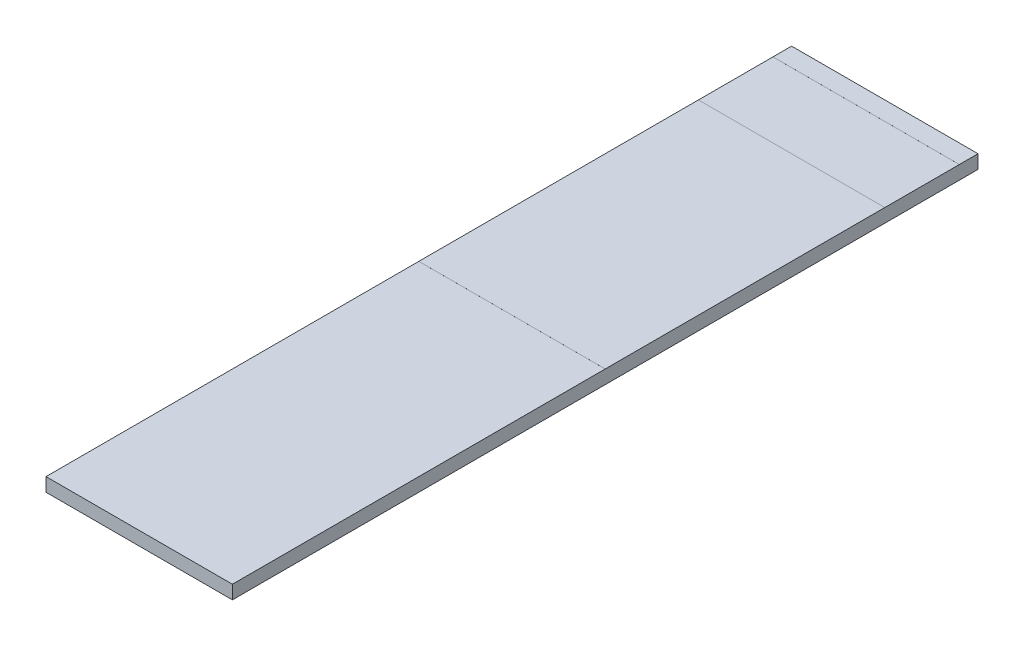
from build123d import *

# Parameters (mm, degrees)
SKETCH1_W           = 1
SKETCH1_H           = 0.072865
BOSS_EXTRUDE1_DEPTH = 4
SKETCH7_W           = 1
SKETCH7_H           = 0.1
SKETCH7_H_2         = 1.5
BOSS_EXTRUDE6_DEPTH = 0.0001
BOSS_EXTRUDE7_START = -0.072865
SKETCH7_2_W         = 1
SKETCH7_2_H         = 0.1
SKETCH7_2_H_2       = 1.5
BOSS_EXTRUDE7_DEPTH = 0.0001


with BuildPart() as part:
    # Sketch1 → Boss-Extrude1 (new body)
    with BuildSketch(Plane.XY):
        with Locations((0.5, 0.0364325)):
            Rectangle(SKETCH1_W, SKETCH1_H)
    extrude(amount=BOSS_EXTRUDE1_DEPTH)

    # Sketch7 → Boss-Extrude6 (add)
    with BuildSketch(Plane(origin=(0, 0.072865, 0), x_dir=(1, 0, 0), z_dir=(0, 1, 0))):
        with Locations((0.5, -0.05)):
            Rectangle(SKETCH7_W, SKETCH7_H)
        with Locations((0.5, -1.25)):
            Rectangle(SKETCH7_W, SKETCH7_H_2)
    extrude(amount=BOSS_EXTRUDE6_DEPTH)

    # Sketch7_2 → Boss-Extrude7 (add)
    with BuildSketch(Plane(origin=(0, 0.072865, 0), x_dir=(1, 0, 0), z_dir=(0, 1, 0)).offset(BOSS_EXTRUDE7_START)):
        with Locations((0.5, -0.05)):
            Rectangle(SKETCH7_2_W, SKETCH7_2_H)
        with Locations((0.5, -1.25)):
            Rectangle(SKETCH7_2_W, SKETCH7_2_H_2)
    extrude(amount=-BOSS_EXTRUDE7_DEPTH)


solid = part.part
